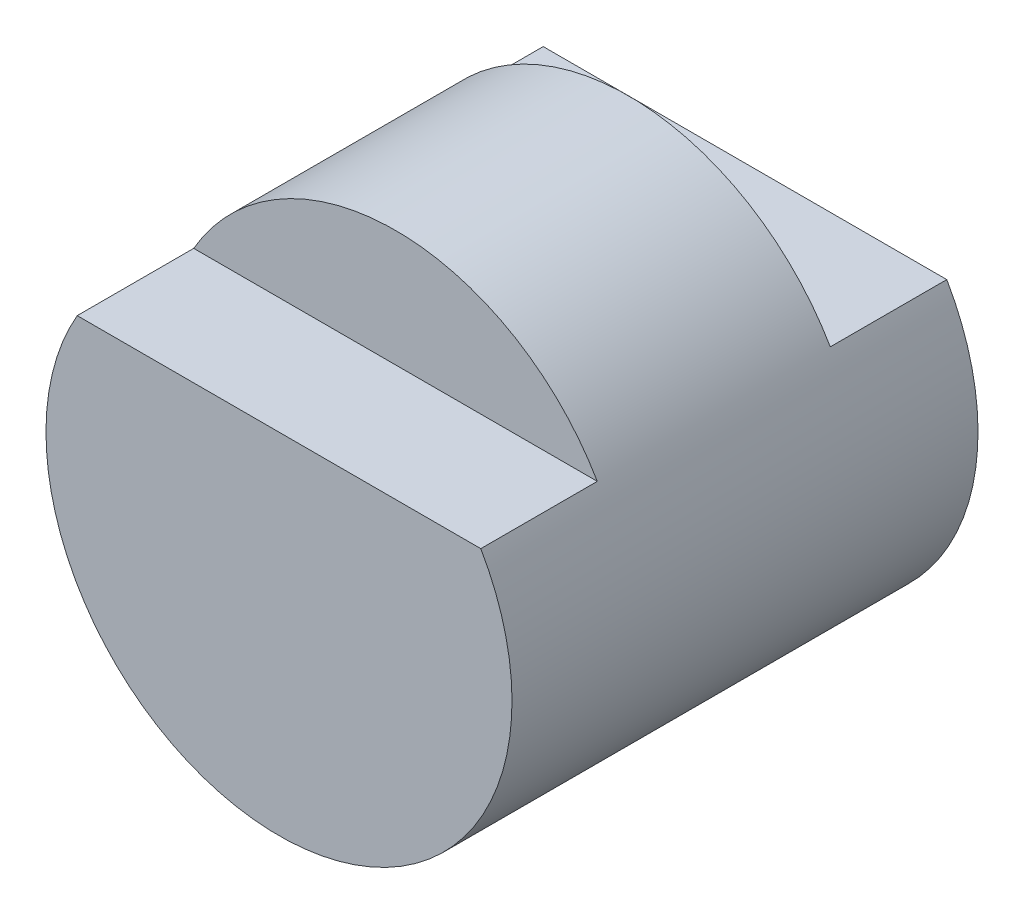
from build123d import *

# Parameters (mm, degrees)
SKETCH1_R           = 2
BOSS_EXTRUDE1_DEPTH = 4
CUT_EXTRUDE1_DEPTH  = 1
CUT_EXTRUDE2_DEPTH  = 1


with BuildPart() as part:
    # Sketch1 → Boss-Extrude1 (new body)
    with BuildSketch(Plane.XY):
        Circle(SKETCH1_R)
    extrude(amount=BOSS_EXTRUDE1_DEPTH)

    # Sketch2 → Cut-Extrude1 (cut)
    with BuildSketch(Plane.XY.offset(4)):
        with BuildLine():
            Line((-1.732050808, 1), (1.732050808, 1))
            ThreePointArc((1.732050808, 1), (0, 2), (-1.732050808, 1))
        make_face()
    extrude(amount=-CUT_EXTRUDE1_DEPTH, mode=Mode.SUBTRACT)

    # Sketch3 → Cut-Extrude2 (cut)
    with BuildSketch(Plane(origin=(0, 0, 0), x_dir=(-1, 0, 0), z_dir=(0, 0, -1))):
        with BuildLine():
            Line((1.732050808, 1), (-1.732050808, 1))
            ThreePointArc((-1.732050808, 1), (0, 2), (1.732050808, 1))
        make_face()
    extrude(amount=-CUT_EXTRUDE2_DEPTH, mode=Mode.SUBTRACT)


solid = part.part
